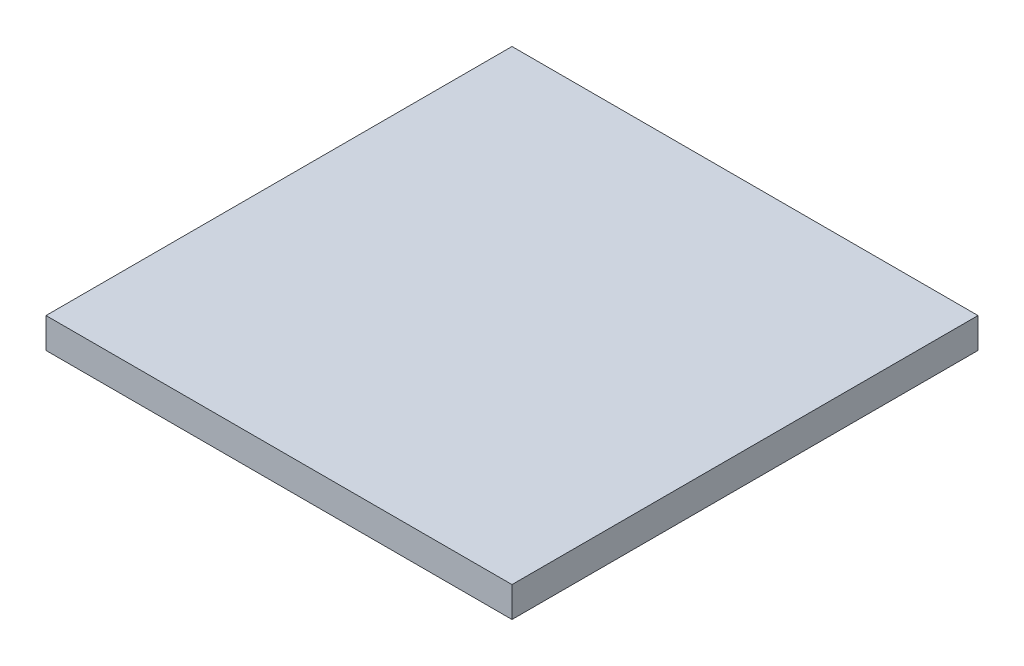
from build123d import *

# Parameters (mm, degrees)
SKETCH1_W           = 5850
SKETCH1_H           = 5850
BOSS_EXTRUDE1_DEPTH = 380


with BuildPart() as part:
    # Sketch1 → Boss-Extrude1 (new body)
    with BuildSketch(Plane(origin=(0, 0, 0), x_dir=(1, 0, 0), z_dir=(0, 1, 0))):
        Rectangle(SKETCH1_W, SKETCH1_H)
    extrude(amount=BOSS_EXTRUDE1_DEPTH)


solid = part.part
